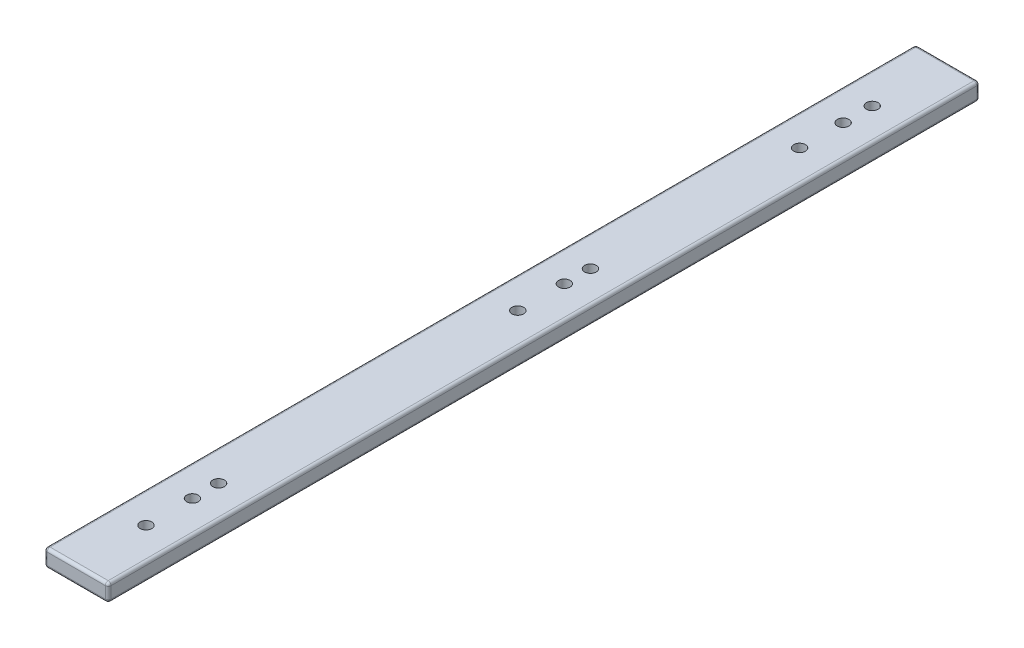
from build123d import *

# Parameters (mm, degrees)
SKETCH1_W           = 22
SKETCH1_H           = 6
BOSS_EXTRUDE1_DEPTH = 300
SKETCH3_R           = 2
CUT_EXTRUDE1_DEPTH  = 6
FILLET1_R           = 1


with BuildPart() as part:
    # Sketch1 → Boss-Extrude1 (new body)
    with BuildSketch(Plane.XY):
        Rectangle(SKETCH1_W, SKETCH1_H)
    extrude(amount=BOSS_EXTRUDE1_DEPTH)

    # Sketch3 → Cut-Extrude1 (cut)
    with BuildSketch(Plane(origin=(0, 3, 0), x_dir=(1, 0, 0), z_dir=(0, 1, 0))):
        with Locations((0, -26)):
            Circle(SKETCH3_R)
        with Locations((0, -36)):
            Circle(SKETCH3_R)
        with Locations((0, -51)):
            Circle(SKETCH3_R)
        with Locations((0, -260)):
            Circle(SKETCH3_R)
        with Locations((0, -276)):
            Circle(SKETCH3_R)
        with Locations((0, -251)):
            Circle(SKETCH3_R)
        with Locations((0, -148)):
            Circle(SKETCH3_R)
        with Locations((0, -123)):
            Circle(SKETCH3_R)
        with Locations((0, -132)):
            Circle(SKETCH3_R)
    extrude(amount=-CUT_EXTRUDE1_DEPTH, mode=Mode.SUBTRACT)

    # Fillet1
    fillet1_edges = [part.edges().sort_by_distance(p)[0] for p in [
        (-11, 0, 300),
        (0, -3, 300),
        (11, 0, 300),
        (0, -3, 0),
        (-11, 0, 0),
        (0, 3, 0),
        (11, 0, 0),
        (0, 3, 300),
        (11, -3, 150),
        (-11, -3, 150),
        (-11, 3, 150),
        (11, 3, 150),
    ]]
    fillet(fillet1_edges, radius=FILLET1_R)


solid = part.part
